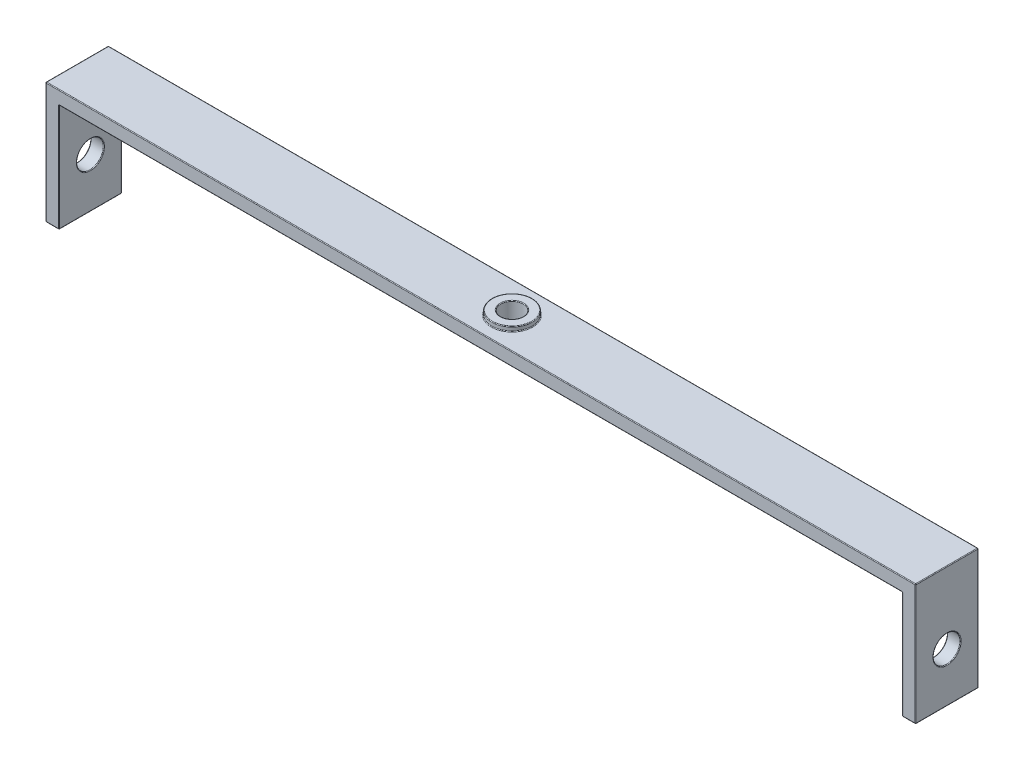
from build123d import *

# Parameters (mm, degrees)
BOSS_EXTRUDE1_DEPTH            = 3.5
SKETCH2_R                      = 1.25
CUT_EXTRUDE1_DEPTH             = 1.5
SKETCH3_R                      = 2.25
SKETCH3_R_2                    = 1.25
BOSS_EXTRUDE2_DEPTH            = 0.5
CUT_EXTRUDE2_REACH             = 50.5
SKETCH4_R                      = 1.5
CUT_EXTRUDE2_DIRECTION_2_REACH = 50.5
FILLET1_R                      = 0.075


with BuildPart() as part:
    # Sketch1 → Boss-Extrude1 (new body, symmetric)
    with BuildSketch(Plane.XY):
        Polygon((-47, 0), (47, 0), (47, -12), (48.5, -12), (48.5, 1.5), (-48.5, 1.5), (-48.5, -12), (-47, -12), align=None)
    extrude(amount=BOSS_EXTRUDE1_DEPTH, both=True)

    # Sketch2 → Cut-Extrude1 (cut)
    with BuildSketch(Plane(origin=(0, 1.5, 0), x_dir=(1, 0, 0), z_dir=(0, 1, 0))):
        Circle(SKETCH2_R)
    extrude(amount=-CUT_EXTRUDE1_DEPTH, mode=Mode.SUBTRACT)

    # Sketch3 → Boss-Extrude2 (add)
    with BuildSketch(Plane(origin=(0, 1.5, 0), x_dir=(1, 0, 0), z_dir=(0, 1, 0))):
        Circle(SKETCH3_R)
        Circle(SKETCH3_R_2, mode=Mode.SUBTRACT)
    extrude(amount=BOSS_EXTRUDE2_DEPTH)

    # Cut-Extrude2: up to this face of the body (flat: up to its plane)
    cut_extrude2_end = Plane(part.part.faces().sort_by_distance((-48.5, -5.25, 0))[0])
    # Sketch4 → Cut-Extrude2 (cut, up to the picked face)
    with BuildSketch(Plane(origin=(0, 0, 0), x_dir=(0, 0, -1), z_dir=(1, 0, 0)), mode=Mode.PRIVATE) as cut_extrude2_sk1:
        with Locations((0, -6.5)):
            Circle(SKETCH4_R)
    cut_extrude2_tool1 = split(extrude(cut_extrude2_sk1.sketch, amount=-CUT_EXTRUDE2_REACH, mode=Mode.PRIVATE), bisect_by=cut_extrude2_end, keep=Keep.BOTH, mode=Mode.PRIVATE)
    add(cut_extrude2_tool1.solids().sort_by_distance((0, -6.5, 0))[0], mode=Mode.SUBTRACT)

    # Cut-Extrude2 direction 2: up to this face of the body (flat: up to its plane)
    cut_extrude2_direction_2_end = Plane(part.part.faces().sort_by_distance((48.5, -5.25, 0))[0])
    # Sketch4 → Cut-Extrude2 direction 2 (cut, up to the picked face)
    with BuildSketch(Plane(origin=(0, 0, 0), x_dir=(0, 0, -1), z_dir=(1, 0, 0)), mode=Mode.PRIVATE) as cut_extrude2_direction_2_sk1:
        with Locations((0, -6.5)):
            Circle(SKETCH4_R)
    cut_extrude2_direction_2_tool1 = split(extrude(cut_extrude2_direction_2_sk1.sketch, amount=CUT_EXTRUDE2_DIRECTION_2_REACH, mode=Mode.PRIVATE), bisect_by=cut_extrude2_direction_2_end, keep=Keep.BOTH, mode=Mode.PRIVATE)
    add(cut_extrude2_direction_2_tool1.solids().sort_by_distance((0, -6.5, 0))[0], mode=Mode.SUBTRACT)

    # Fillet1
    fillet1_edges = [part.edges().sort_by_distance(p)[0] for p in [
        (47.75, -12, -3.5),
        (47, -6, -3.5),
        (0, 0, -3.5),
        (-47, -6, -3.5),
        (47, -6, 3.5),
        (-47, -12, 0),
        (-48.5, -12, 0),
        (-48.5, 1.5, 0),
        (48.5, 1.5, 0),
        (48.5, -12, 0),
        (47, -12, 0),
        (47, 0, 0),
        (-47, 0, 0),
        (47.75, -12, 3.5),
        (48.5, -5.25, 3.5),
        (0, 1.5, 3.5),
        (-1.25, 0, 0),
        (-48.5, -5.25, 3.5),
        (-2.25, 1.5, 0),
        (-2.25, 2, 0),
        (-1.25, 2, 0),
        (-47.75, -12, 3.5),
        (-47, -6.5, 1.5),
        (48.5, -6.5, 1.5),
        (47, -6.5, 1.5),
        (-48.5, -6.5, 1.5),
        (-47, -6, 3.5),
        (-47.75, -12, -3.5),
        (0, 0, 3.5),
        (-48.5, -5.25, -3.5),
        (0, 1.5, -3.5),
        (48.5, -5.25, -3.5),
    ]]
    fillet(fillet1_edges, radius=FILLET1_R)


solid = part.part
